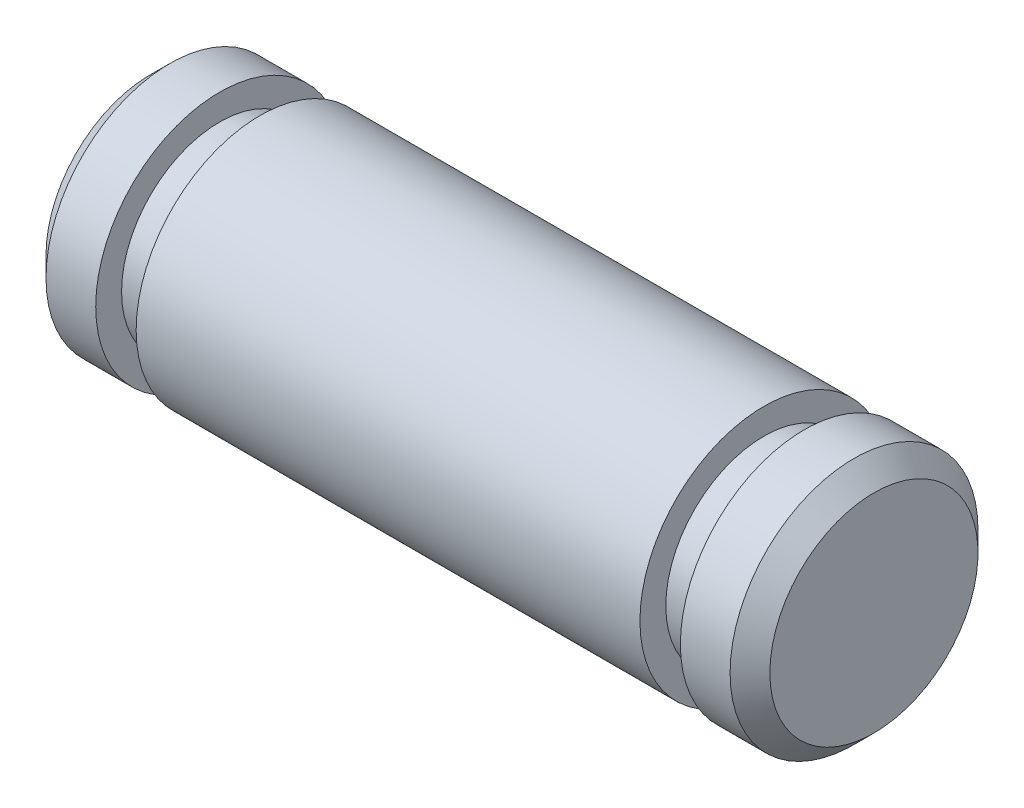
from build123d import *


with BuildPart() as part:
    # Sketch1 → Revolve1 (revolve)
    with BuildSketch(Plane.XY):
        Polygon((-6.9342, 0), (-6.9342, 1.9939), (-6.5532, 2.3749), (-5.6007, 2.3749), (-5.6007, 1.8796), (-4.826, 1.8796), (-4.826, 2.3749), (4.826, 2.3749), (4.826, 1.8796), (5.6007, 1.8796), (5.6007, 2.3749), (6.5532, 2.3749), (6.9342, 1.9939), (6.9342, 0), align=None)
    revolve(axis=Axis((6.9342, 0, 0), (-1, 0, 0)))


solid = part.part
